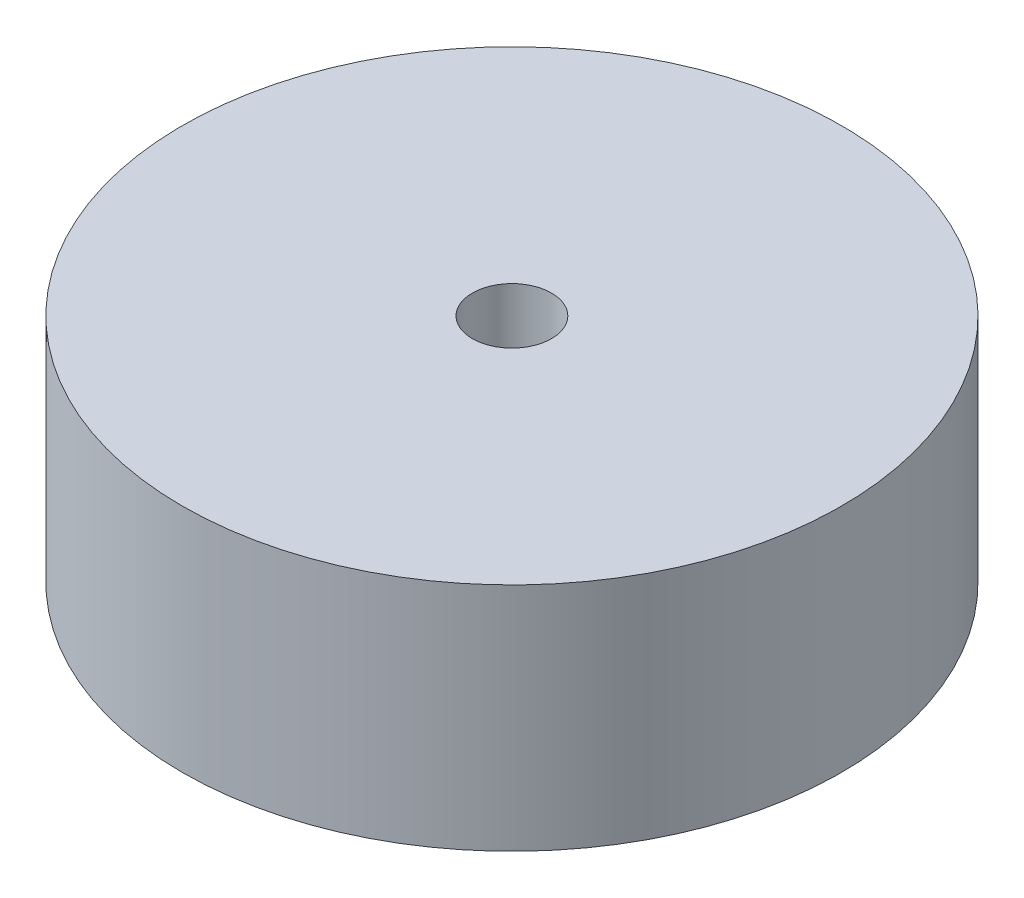
from build123d import *

# Parameters (mm, degrees)
SKETCH1_R           = 50
SKETCH1_R_2         = 6
BOSS_EXTRUDE1_DEPTH = 35


with BuildPart() as part:
    # Sketch1 → Boss-Extrude1 (new body)
    with BuildSketch(Plane(origin=(0, 0, 0), x_dir=(1, 0, 0), z_dir=(0, 1, 0))):
        Circle(SKETCH1_R)
        Circle(SKETCH1_R_2, mode=Mode.SUBTRACT)
    extrude(amount=BOSS_EXTRUDE1_DEPTH)


solid = part.part
